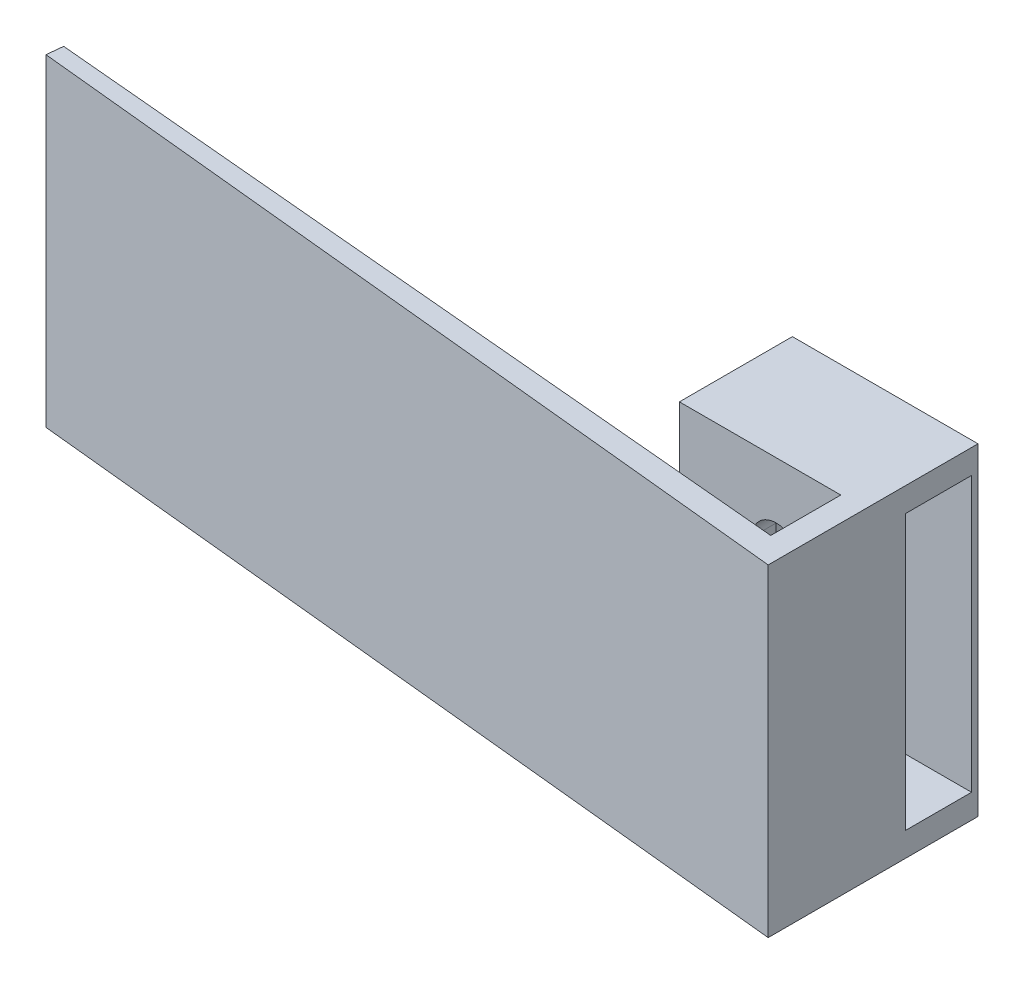
from build123d import *

# Parameters (mm, degrees)
SALIENTE_EXTRUIR1_DEPTH = 20
CROQUIS4_W              = 8
CROQUIS4_H              = 17
CORTAR_EXTRUIR2_DEPTH   = 5.5
CROQUIS4_4_W            = 1.5
CROQUIS4_4_H            = 17
CORTAR_EXTRUIR3_DEPTH   = 4.5
CORTAR_EXTRUIR4_REACH   = 56.141
SALIENTE_EXTRUIR3_REACH = 56.646
CROQUIS7_W              = 9.5
CROQUIS7_H              = 0.4


with BuildPart() as part:
    # Croquis1 → Saliente-Extruir1 (new body)
    with BuildSketch(Plane(origin=(0, 0, 0), x_dir=(1, 0, 0), z_dir=(0, 1, 0))):
        Polygon((-11.5, 13), (0, 13), (0, 0), (-49.748866803, 5.005022664), (-49.648766349, 6), (-1.5, 1.658480671), (-1.5, 6), (-11.5, 6), align=None)
    extrude(amount=SALIENTE_EXTRUIR1_DEPTH)

    # Croquis4 → Cortar-Extruir2 (cut)
    with BuildSketch(Plane(origin=(0, 0, -13), x_dir=(-1, 0, 0), z_dir=(0, 0, -1))):
        with Locations((5.5, 10)):
            Rectangle(CROQUIS4_W, CROQUIS4_H)
    extrude(amount=-CORTAR_EXTRUIR2_DEPTH, mode=Mode.SUBTRACT)

    # Croquis4_4 → Cortar-Extruir3 (cut)
    with BuildSketch(Plane(origin=(0, 0, -13), x_dir=(-1, 0, 0), z_dir=(0, 0, -1))):
        with Locations((0.75, 10)):
            Rectangle(CROQUIS4_4_W, CROQUIS4_4_H)
    extrude(amount=-CORTAR_EXTRUIR3_DEPTH, mode=Mode.SUBTRACT)

    # Croquis6 → Cortar-Extruir4 (cut, up to next)
    with BuildSketch(Plane(origin=(0, 0, -7.5), x_dir=(-1, 0, 0), z_dir=(0, 0, -1)), mode=Mode.PRIVATE) as cortar_extruir4_sk1:
        with BuildLine():
            Line((7, 15), (7, 5))
            ThreePointArc((7, 5), (5.5, 3.5), (4, 5))
            Line((4, 5), (4, 15))
            ThreePointArc((4, 15), (5.5, 16.5), (7, 15))
        make_face()
    cortar_extruir4_tool1 = extrude(cortar_extruir4_sk1.sketch, amount=-CORTAR_EXTRUIR4_REACH, mode=Mode.PRIVATE) & part.part
    add(cortar_extruir4_tool1.solids().sort_by_distance((-5.5, 10, -7.5))[0], mode=Mode.SUBTRACT)

    # Croquis7 → Saliente-Extruir3 (add, up to next)
    with BuildSketch(Plane(origin=(0, 1.5, 0), x_dir=(1, 0, 0), z_dir=(0, 1, 0)), mode=Mode.PRIVATE) as saliente_extruir3_sk1:
        with Locations((-4.75, 12.8)):
            Rectangle(CROQUIS7_W, CROQUIS7_H)
    saliente_extruir3_tool1 = extrude(saliente_extruir3_sk1.sketch, amount=SALIENTE_EXTRUIR3_REACH, mode=Mode.PRIVATE) - part.part
    add(saliente_extruir3_tool1.solids().sort_by_distance((-4.75, 1.5, -12.8))[0])


solid = part.part
